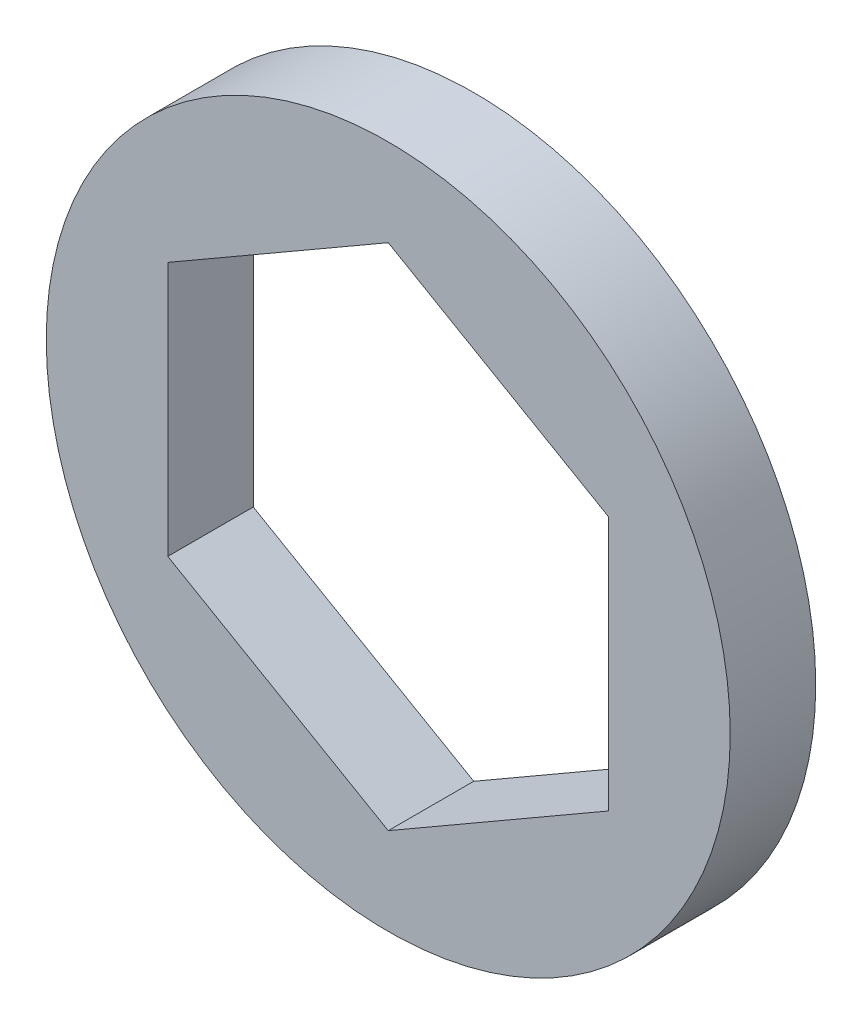
from build123d import *

# Parameters (mm, degrees)
SKETCH1_R           = 10.16
BOSS_EXTRUDE1_DEPTH = 2.54


with BuildPart() as part:
    # Sketch1 → Boss-Extrude1 (new body)
    with BuildSketch(Plane.XY):
        Circle(SKETCH1_R)
        Polygon((0, 7.563288526), (-6.55, 3.781644263), (-6.55, -3.781644263), (0, -7.563288526), (6.55, -3.781644263), (6.55, 3.781644263), align=None, mode=Mode.SUBTRACT)
    extrude(amount=BOSS_EXTRUDE1_DEPTH)


solid = part.part
